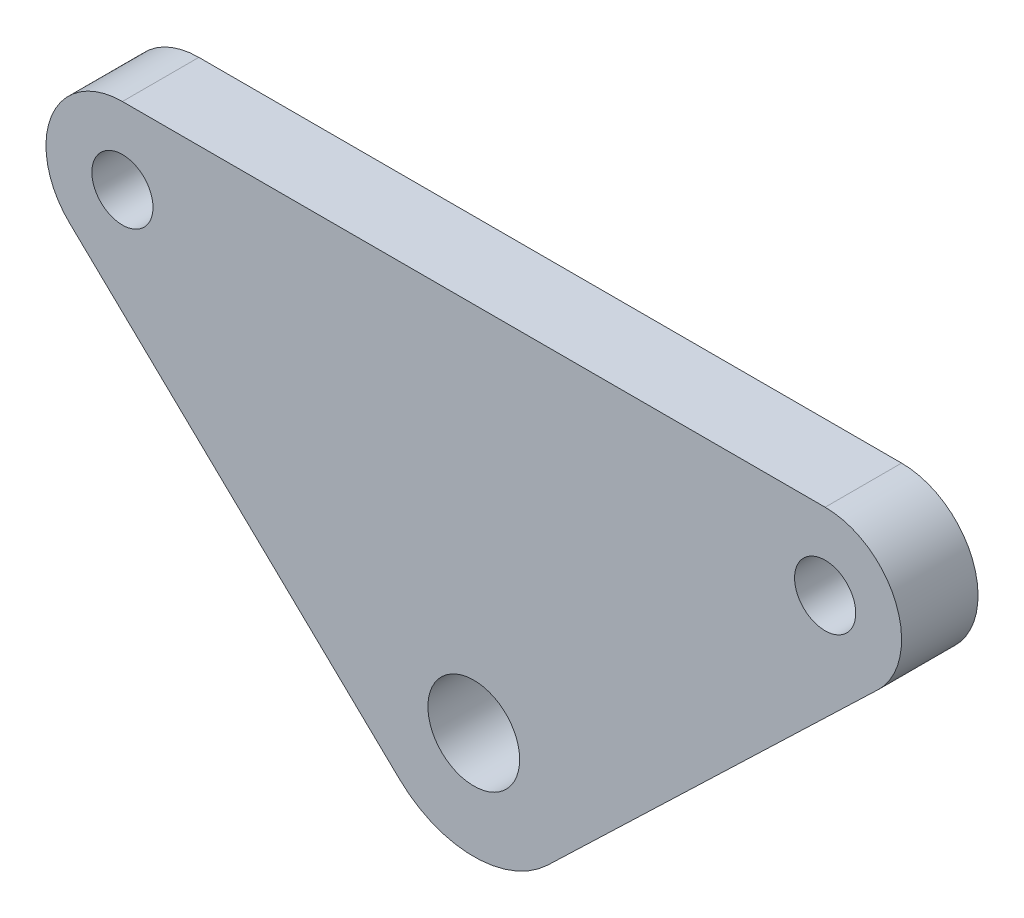
from build123d import *

# Parameters (mm, degrees)
BOSS_EXTRUDE1_START = -10
SKETCH1_R           = 3
SKETCH1_R_2         = 2
BOSS_EXTRUDE1_DEPTH = 5


with BuildPart() as part:
    # Sketch1 → Boss-Extrude1 (new body)
    with BuildSketch(Plane.XY.offset(BOSS_EXTRUDE1_START)):
        with BuildLine():
            Line((-125.350212025, 161.26892377), (-79.387545438, 161.26892377))
            ThreePointArc((-79.387545438, 161.26892377), (-74.748731312, 158.134775723), (-75.92540928, 152.661485175))
            Line((-75.92540928, 152.661485175), (-97.52188811, 131.934881446))
            ThreePointArc((-97.52188811, 131.934881446), (-102.368878731, 129.98529548), (-107.215869353, 131.934881446))
            Line((-107.215869353, 131.934881446), (-128.812348183, 152.661485175))
            ThreePointArc((-128.812348183, 152.661485175), (-129.98902615, 158.134775723), (-125.350212025, 161.26892377))
        make_face()
        with Locations((-102.368878731, 136.98529548)):
            Circle(SKETCH1_R, mode=Mode.SUBTRACT)
        with Locations((-79.387545438, 156.26892377)):
            Circle(SKETCH1_R_2, mode=Mode.SUBTRACT)
        with Locations((-125.350212025, 156.26892377)):
            Circle(SKETCH1_R_2, mode=Mode.SUBTRACT)
    extrude(amount=-BOSS_EXTRUDE1_DEPTH)


solid = part.part
